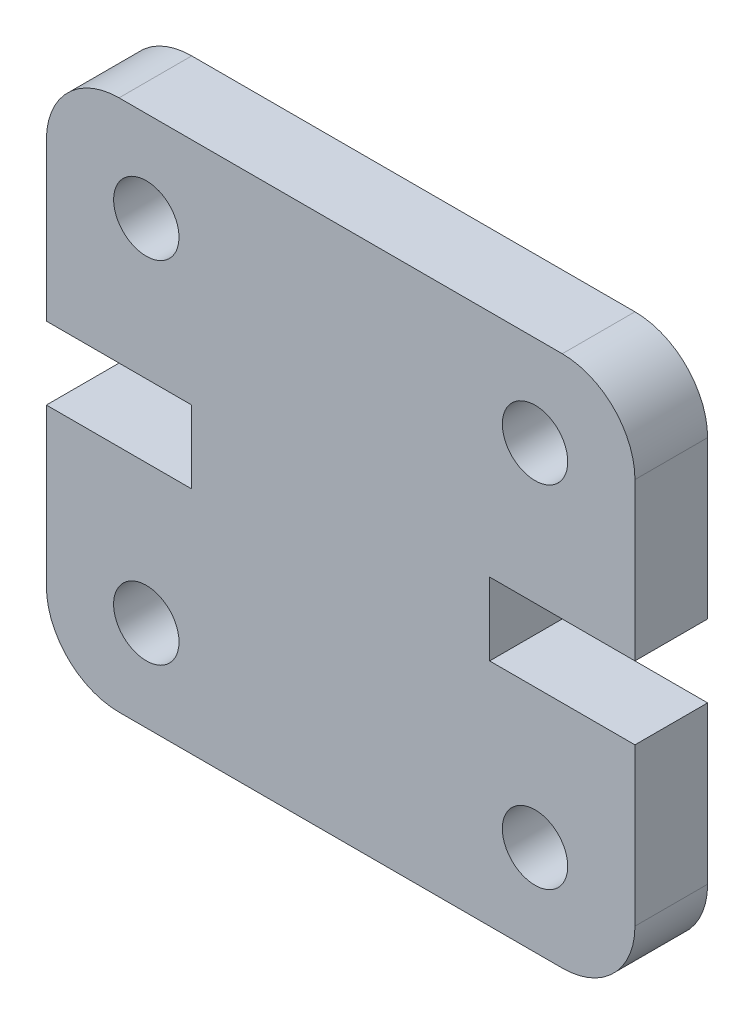
from build123d import *

# Parameters (mm, degrees)
SKETCH1_R           = 0.9
BOSS_EXTRUDE1_DEPTH = 4
SKETCH2_W           = 16.2
SKETCH2_H           = 14.645
CUT_EXTRUDE1_DEPTH  = 2


with BuildPart() as part:
    # Sketch1 → Boss-Extrude1 (new body)
    with BuildSketch(Plane.XY):
        with BuildLine():
            Line((2, 14.645), (14.2, 14.645))
            ThreePointArc((14.2, 14.645), (15.614213562, 14.059213562), (16.2, 12.645))
            Line((16.2, 12.645), (16.2, 8.3225))
            Line((16.2, 8.3225), (12.2, 8.3225))
            Line((12.2, 8.3225), (12.2, 6.3225))
            Line((12.2, 6.3225), (16.2, 6.3225))
            Line((16.2, 6.3225), (16.2, 2))
            ThreePointArc((16.2, 2), (15.614213562, 0.585786438), (14.2, 0))
            Line((14.2, 0), (2, 0))
            ThreePointArc((2, 0), (0.585786438, 0.585786438), (0, 2))
            Line((0, 2), (0, 6.3225))
            Line((0, 6.3225), (4, 6.3225))
            Line((4, 6.3225), (4, 8.3225))
            Line((4, 8.3225), (0, 8.3225))
            Line((0, 8.3225), (0, 12.645))
            ThreePointArc((0, 12.645), (0.585786438, 14.059213562), (2, 14.645))
        make_face()
        with Locations((2.75, 12.145)):
            Circle(SKETCH1_R, mode=Mode.SUBTRACT)
        with Locations((13.45, 2.5)):
            Circle(SKETCH1_R, mode=Mode.SUBTRACT)
        with Locations((13.45, 12.145)):
            Circle(SKETCH1_R, mode=Mode.SUBTRACT)
        with Locations((2.75, 2.5)):
            Circle(SKETCH1_R, mode=Mode.SUBTRACT)
    extrude(amount=BOSS_EXTRUDE1_DEPTH)

    # Sketch2 → Cut-Extrude1 (cut)
    with BuildSketch(Plane(origin=(0, 0, 0), x_dir=(-1, 0, 0), z_dir=(0, 0, -1))):
        with Locations((-8.1, 7.3225)):
            Rectangle(SKETCH2_W, SKETCH2_H)
    extrude(amount=-CUT_EXTRUDE1_DEPTH, mode=Mode.SUBTRACT)


solid = part.part
